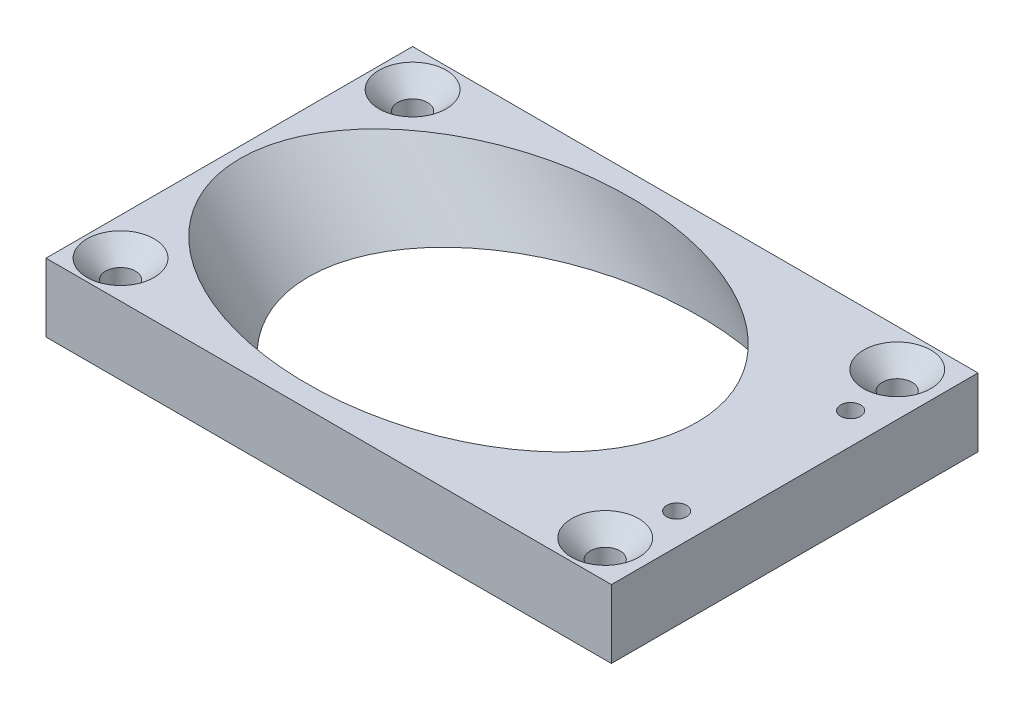
from build123d import *

# Parameters (mm, degrees)
SKETCH1_W                                           = 45.5
SKETCH1_H                                           = 29.5
BOSS_EXTRUDE1_DEPTH                                 = 5.5
CUT_EXTRUDE1_REACH                                  = 38.062
SKETCH2_R                                           = 13
CSK_FOR_M2_COUNTERSUNK_FLAT_HEAD_SCREW1_D           = 2.4
CSK_FOR_M2_COUNTERSUNK_FLAT_HEAD_SCREW1_CSINK_D     = 5.4
CSK_FOR_M2_COUNTERSUNK_FLAT_HEAD_SCREW1_CSINK_ANGLE = 90
M2_TAPPED_HOLE1_D                                   = 1.6


with BuildPart() as part:
    # Sketch1 → Boss-Extrude1 (new body)
    with BuildSketch(Plane(origin=(0, 0, 0), x_dir=(1, 0, 0), z_dir=(0, 1, 0))):
        Rectangle(SKETCH1_W, SKETCH1_H)
    extrude(amount=BOSS_EXTRUDE1_DEPTH)

    # Sketch2 → Cut-Extrude1 (cut, up to next)
    with BuildSketch(Plane(origin=(-14.125, 14.125, 0), x_dir=(0, 0, 1), z_dir=(-0.707106781, 0.707106781, 0)), mode=Mode.PRIVATE) as cut_extrude1_sk1:
        with Locations((0, 1.413320728)):
            Circle(SKETCH2_R)
    cut_extrude1_tool1 = extrude(cut_extrude1_sk1.sketch, amount=-CUT_EXTRUDE1_REACH, mode=Mode.PRIVATE) & part.part
    add(cut_extrude1_tool1.solids().sort_by_distance((-13.125631, 15.124369, 0))[0], mode=Mode.SUBTRACT)

    # CSK for M2 Countersunk Flat Head Screw1 (through all)
    with Locations(Plane(origin=(0, 5.5, 0), x_dir=(1, 0, 0), z_dir=(0, 1, 0))):
        with Locations((-19.75, 11.75), (19.25, 11.75), (-19.75, -11.75), (19.25, -11.75)):
            CounterSinkHole(CSK_FOR_M2_COUNTERSUNK_FLAT_HEAD_SCREW1_D / 2, CSK_FOR_M2_COUNTERSUNK_FLAT_HEAD_SCREW1_CSINK_D / 2, counter_sink_angle=CSK_FOR_M2_COUNTERSUNK_FLAT_HEAD_SCREW1_CSINK_ANGLE)

    # M2 Tapped Hole1 (through all)
    with Locations(Plane(origin=(0, 5.5, 0), x_dir=(1, 0, 0), z_dir=(0, 1, 0))):
        with Locations((20.25, 7), (20.25, -7)):
            Hole(M2_TAPPED_HOLE1_D / 2)


solid = part.part
